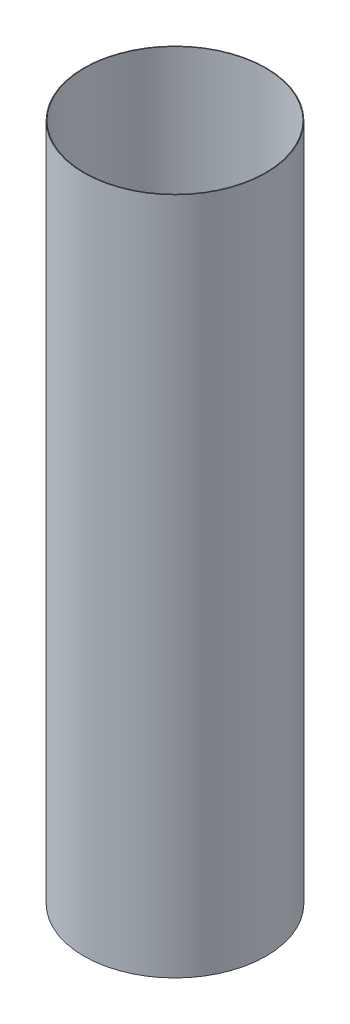
from build123d import *

# Parameters (mm, degrees)
SKETCH1_R           = 77.216
SKETCH1_R_2         = 76.708
BOSS_EXTRUDE1_DEPTH = 574.708528


with BuildPart() as part:
    # Sketch1 → Boss-Extrude1 (new body)
    with BuildSketch(Plane(origin=(0, 0, 0), x_dir=(1, 0, 0), z_dir=(0, 1, 0))):
        Circle(SKETCH1_R)
        Circle(SKETCH1_R_2, mode=Mode.SUBTRACT)
    extrude(amount=BOSS_EXTRUDE1_DEPTH)


solid = part.part
